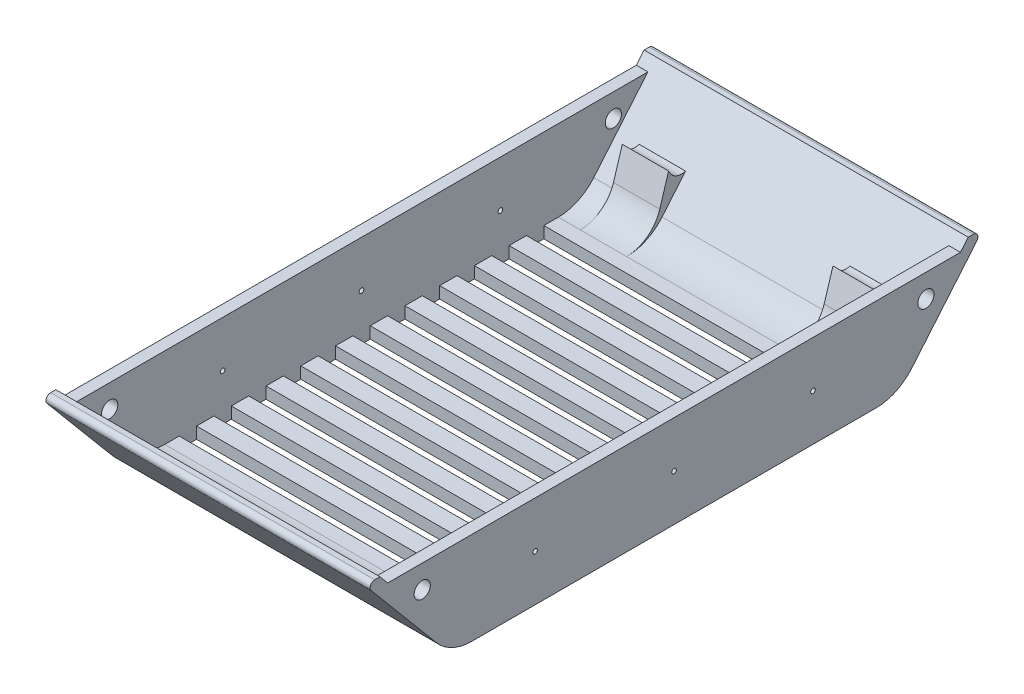
from build123d import *

# Parameters (mm, degrees)
BOSS_EXTRUDE4_DEPTH          = 70
BOSS_EXTRU_5_DEPTH           = 55.5
BOSS_EXTRU_5_DEPTH_BACK      = 55.5
ENL_V_MAT_EXTRU_3_DEPTH      = 35.5
ENL_V_MAT_EXTRU_3_DEPTH_BACK = 35.5
BOSS_EXTRU_3_REACH           = 156.068
ESQUISSE9_W                  = 5
ESQUISSE9_H                  = 247.389280508
ESQUISSE8_R                  = 1
ENL_V_MAT_EXTRU_1_DEPTH      = 156.154173773
ENL_V_MAT_EXTRU_1_DEPTH_BACK = 156.154173773
ESQUISSE17_W                 = 130
ESQUISSE17_H                 = 7.5
ENL_V_MAT_EXTRU_2_DEPTH      = 154.81098023
ENL_V_MAT_EXTRU_2_DEPTH_BACK = 154.81098023
ESQUISSE19_R                 = 3.5
ENL_V_MAT_EXTRU_4_DEPTH      = 194.385153616


with BuildPart() as part:
    # Sketch4 → Boss-Extrude4 (new, symmetric)
    with BuildSketch(Plane(origin=(0, 0, 0), x_dir=(0, 0, -1), z_dir=(1, 0, 0))):
        with BuildLine():
            Line((0, 0), (87.331538291, 0))
            ThreePointArc((87.331538291, 0), (95.783903526, 1.873844259), (102.652427153, 7.144247806))
            Line((102.652427153, 7.144247806), (130.821150271, 40.714424781))
            ThreePointArc((130.821150271, 40.714424781), (131.101676959, 42.845236523), (129.289061385, 44))
            Line((129.289061385, 44), (127.051038779, 44))
            Line((127.051038779, 44), (100.320888862, 12.144247806))
            ThreePointArc((100.320888862, 12.144247806), (93.452365235, 6.873844259), (85, 5))
            Line((85, 5), (0, 5))
            Line((0, 5), (0, 0))
        make_face()
    boss_extrude4 = extrude(amount=BOSS_EXTRUDE4_DEPTH, both=True)

    # Esquisse15 → Boss.-Extru.5 (add, two sides)
    with BuildSketch(Plane(origin=(0, 0, 0), x_dir=(0, 0, -1), z_dir=(1, 0, 0))) as boss_extru_5_sk:
        with BuildLine():
            Line((100.320888862, 12.144247806), (110.47494439, 24.245379961))
            ThreePointArc((110.47494439, 24.245379961), (106.073337597, 24.643477634), (103.138451771, 27.94787914))
            Line((103.138451771, 27.94787914), (99.337028752, 15.589829192))
            ThreePointArc((99.337028752, 15.589829192), (93.911998594, 7.934500381), (85, 5))
            ThreePointArc((85, 5), (93.452365235, 6.873844259), (100.320888862, 12.144247806))
        make_face()
    extrude(amount=BOSS_EXTRU_5_DEPTH)
    extrude(boss_extru_5_sk.sketch, amount=-BOSS_EXTRU_5_DEPTH_BACK)

    # Esquisse18 → Enlèv. mat.-Extru.3 (cut, two sides)
    with BuildSketch(Plane(origin=(0, 0, 0), x_dir=(0, 0, -1), z_dir=(1, 0, 0))) as enl_v_mat_extru_3_sk:
        with BuildLine():
            Line((100.320888862, 12.144247806), (110.47494439, 24.245379961))
            ThreePointArc((110.47494439, 24.245379961), (106.073337597, 24.643477634), (103.138451771, 27.94787914))
            Line((103.138451771, 27.94787914), (99.337028752, 15.589829192))
            ThreePointArc((99.337028752, 15.589829192), (93.911998594, 7.934500381), (85, 5))
            ThreePointArc((85, 5), (93.452365235, 6.873844259), (100.320888862, 12.144247806))
        make_face()
    extrude(amount=ENL_V_MAT_EXTRU_3_DEPTH, mode=Mode.SUBTRACT)
    extrude(enl_v_mat_extru_3_sk.sketch, amount=-ENL_V_MAT_EXTRU_3_DEPTH_BACK, mode=Mode.SUBTRACT)

    # Mirror2: Boss-Extrude4 across plane
    add(boss_extrude4.mirror(Plane(origin=(70, 5, 0), x_dir=(1, 0, 0), z_dir=(0, 0, -1))))

    # Esquisse9 → Boss.-Extru.3 (add, up to next)
    with BuildSketch(Plane(origin=(0, 40, 0), x_dir=(1, 0, 0), z_dir=(0, 1, 0)), mode=Mode.PRIVATE) as boss_extru_3_sk1:
        with Locations((67.5, 0)):
            Rectangle(ESQUISSE9_W, ESQUISSE9_H)
    boss_extru_3_tool1 = extrude(boss_extru_3_sk1.sketch, amount=-BOSS_EXTRU_3_REACH, mode=Mode.PRIVATE) - part.part
    # Esquisse9 → Boss.-Extru.3 (add, up to next)
    with BuildSketch(Plane(origin=(0, 40, 0), x_dir=(1, 0, 0), z_dir=(0, 1, 0)), mode=Mode.PRIVATE) as boss_extru_3_sk2:
        with Locations((-67.5, 0)):
            Rectangle(ESQUISSE9_W, ESQUISSE9_H)
    boss_extru_3_tool2 = extrude(boss_extru_3_sk2.sketch, amount=-BOSS_EXTRU_3_REACH, mode=Mode.PRIVATE) - part.part
    add(boss_extru_3_tool1.solids().sort_by_distance((67.5, 40, 0))[0])
    add(boss_extru_3_tool2.solids().sort_by_distance((-67.5, 40, 0))[0])

    # Esquisse8 → Enlèv. mat.-Extru.1 (cut, two sides)
    with BuildSketch(Plane(origin=(0, 0, 0), x_dir=(0, 0, -1), z_dir=(1, 0, 0))) as enl_v_mat_extru_1_sk:
        with Locations((0, 20)):
            Circle(ESQUISSE8_R)
        with Locations((60, 20)):
            Circle(ESQUISSE8_R)
        with Locations((-60, 20)):
            Circle(ESQUISSE8_R)
    extrude(amount=ENL_V_MAT_EXTRU_1_DEPTH, mode=Mode.SUBTRACT)
    extrude(enl_v_mat_extru_1_sk.sketch, amount=-ENL_V_MAT_EXTRU_1_DEPTH_BACK, mode=Mode.SUBTRACT)

    # Esquisse17 → Enlèv. mat.-Extru.2 (cut, two sides)
    with BuildSketch(Plane(origin=(0, 5, 0), x_dir=(1, 0, 0), z_dir=(0, 1, 0))) as enl_v_mat_extru_2_sk:
        Rectangle(ESQUISSE17_W, ESQUISSE17_H)
        with Locations((0, 15)):
            Rectangle(ESQUISSE17_W, ESQUISSE17_H)
        with Locations((0, 30)):
            Rectangle(ESQUISSE17_W, ESQUISSE17_H)
        with Locations((0, 45)):
            Rectangle(ESQUISSE17_W, ESQUISSE17_H)
        with Locations((0, 60)):
            Rectangle(ESQUISSE17_W, ESQUISSE17_H)
        with Locations((0, 75)):
            Rectangle(ESQUISSE17_W, ESQUISSE17_H)
        with Locations((0, -15)):
            Rectangle(ESQUISSE17_W, ESQUISSE17_H)
        with Locations((0, -30)):
            Rectangle(ESQUISSE17_W, ESQUISSE17_H)
        with Locations((0, -45)):
            Rectangle(ESQUISSE17_W, ESQUISSE17_H)
        with Locations((0, -60)):
            Rectangle(ESQUISSE17_W, ESQUISSE17_H)
        with Locations((0, -75)):
            Rectangle(ESQUISSE17_W, ESQUISSE17_H)
    extrude(amount=ENL_V_MAT_EXTRU_2_DEPTH, mode=Mode.SUBTRACT)
    extrude(enl_v_mat_extru_2_sk.sketch, amount=-ENL_V_MAT_EXTRU_2_DEPTH_BACK, mode=Mode.SUBTRACT)

    # Esquisse19 → Enlèv. mat.-Extru.4 (cut, symmetric)
    with BuildSketch(Plane(origin=(-65, 0, 0), x_dir=(0, 0, -1), z_dir=(1, 0, 0))):
        with Locations((108.777551806, 30.001125385)):
            Circle(ESQUISSE19_R)
    enl_v_mat_extru_4 = extrude(amount=ENL_V_MAT_EXTRU_4_DEPTH, both=True, mode=Mode.SUBTRACT)

    # Symétrie1: Enlèv. mat.-Extru.4 across plane
    add(enl_v_mat_extru_4.mirror(Plane.XY), mode=Mode.SUBTRACT)


solid = part.part
